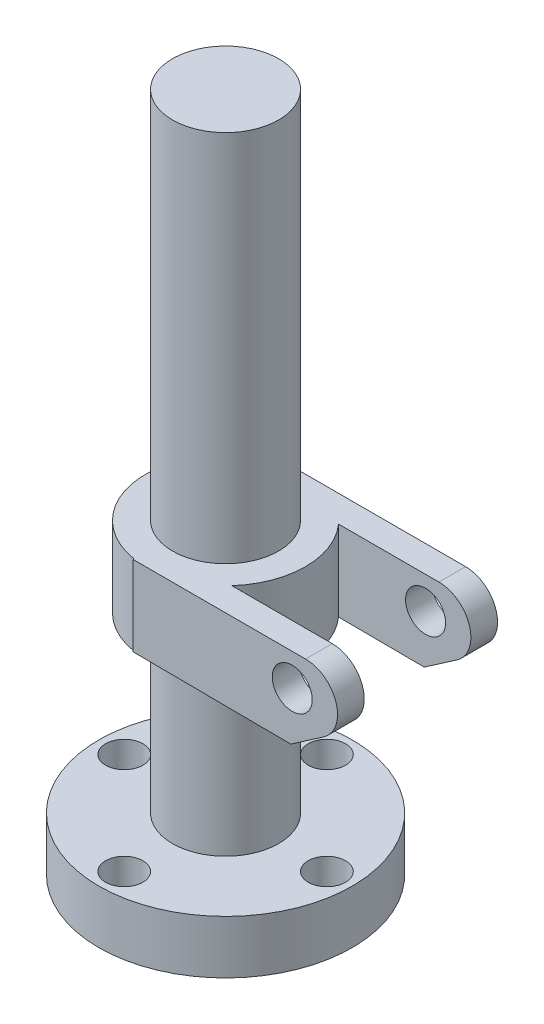
from build123d import *

# Parameters (mm, degrees)
SKETCH1_R                               = 47.5
BOSS_EXTRUDE1_DEPTH                     = 20
SKETCH2_R                               = 19.9
BOSS_EXTRUDE2_DEPTH                     = 65
SKETCH3_R                               = 30
BOSS_EXTRUDE3_DEPTH                     = 30
SKETCH4_R                               = 19.9
BOSS_EXTRUDE4_DEPTH                     = 140
BOSS_EXTRUDE5_DEPTH                     = 30
BOSS_EXTRUDE5_DEPTH_BACK                = 30
CUT_EXTRUDE1_START                      = -40
CUT_EXTRUDE1_DEPTH                      = 40
SKETCH7_R                               = 7.5
CUT_EXTRUDE2_DEPTH                      = 277.071095916
SKETCH8_R                               = 20
CUT_EXTRUDE3_DEPTH                      = 15
CBORE_FOR_M5_HEX_HEAD_BOLT3_D           = 10
CBORE_FOR_M5_HEX_HEAD_BOLT3_CBORE_D     = 14
CBORE_FOR_M5_HEX_HEAD_BOLT3_CBORE_DEPTH = 10
CIRPATTERN1_COUNT                       = 4


with BuildPart() as part:
    # Sketch1 → Boss-Extrude1 (new body)
    with BuildSketch(Plane(origin=(0, 0, 0), x_dir=(1, 0, 0), z_dir=(0, 1, 0))):
        Circle(SKETCH1_R)
    extrude(amount=BOSS_EXTRUDE1_DEPTH)

    # Sketch2 → Boss-Extrude2 (add)
    with BuildSketch(Plane(origin=(0, 20, 0), x_dir=(1, 0, 0), z_dir=(0, 1, 0))):
        Circle(SKETCH2_R)
    extrude(amount=BOSS_EXTRUDE2_DEPTH)

    # Sketch3 → Boss-Extrude3 (add)
    with BuildSketch(Plane(origin=(0, 85, 0), x_dir=(1, 0, 0), z_dir=(0, 1, 0))):
        Circle(SKETCH3_R)
    extrude(amount=BOSS_EXTRUDE3_DEPTH)

    # Sketch4 → Boss-Extrude4 (add)
    with BuildSketch(Plane(origin=(0, 115, 0), x_dir=(1, 0, 0), z_dir=(0, 1, 0))):
        Circle(SKETCH4_R)
    extrude(amount=BOSS_EXTRUDE4_DEPTH)

    # Sketch5 → Boss-Extrude5 (add, two sides: drawn at the far end of the back side and taken through both)
    with BuildSketch(Plane.XY.offset(-BOSS_EXTRUDE5_DEPTH_BACK)):
        with BuildLine():
            Line((-4.684895629, 115), (60, 115))
            ThreePointArc((60, 115), (71.456034828, 106.572011481), (66.820181321, 93.126544336))
            Line((66.820181321, 93.126544336), (54.485559633, 84.606289695))
            Line((54.485559633, 84.606289695), (-4.684895629, 85))
            Line((-4.684895629, 85), (-4.684895629, 115))
        make_face()
    extrude(amount=BOSS_EXTRUDE5_DEPTH + BOSS_EXTRUDE5_DEPTH_BACK)

    # Sketch6 → Cut-Extrude1 (cut)
    with BuildSketch(Plane(origin=(0, 115, 0), x_dir=(1, 0, 0), z_dir=(0, 1, 0)).offset(CUT_EXTRUDE1_START)):
        with BuildLine():
            Line((85.613181264, 20), (85.613181264, -20))
            Line((85.613181264, -20), (22.360679775, -20))
            ThreePointArc((22.360679775, -20), (30, 0), (22.360679775, 20))
            Line((22.360679775, 20), (85.613181264, 20))
        make_face()
    extrude(amount=CUT_EXTRUDE1_DEPTH, mode=Mode.SUBTRACT)

    # Sketch7 → Cut-Extrude2 (cut, through all)
    with BuildSketch(Plane.XY.offset(30)):
        with Locations((55, 103)):
            Circle(SKETCH7_R)
    extrude(amount=-CUT_EXTRUDE2_DEPTH, mode=Mode.SUBTRACT)

    # Sketch8 → Cut-Extrude3 (cut)
    with BuildSketch(Plane.XZ):
        Circle(SKETCH8_R)
    extrude(amount=-CUT_EXTRUDE3_DEPTH, mode=Mode.SUBTRACT)

    # CBORE for M5 Hex Head Bolt3 (through all)
    with Locations(Plane(origin=(0, 20, 0), x_dir=(1, 0, 0), z_dir=(0, 1, 0))):
        with Locations((0, 38)):
            cbore_for_m5_hex_head_bolt3 = CounterBoreHole(CBORE_FOR_M5_HEX_HEAD_BOLT3_D / 2, CBORE_FOR_M5_HEX_HEAD_BOLT3_CBORE_D / 2, CBORE_FOR_M5_HEX_HEAD_BOLT3_CBORE_DEPTH)

    # CirPattern1: CBORE for M5 Hex Head Bolt3 ×4 about axis
    cirpattern1_axis = Axis((0, 20, 0), (0, 1, 0))
    for i in range(1, CIRPATTERN1_COUNT):
        add(cbore_for_m5_hex_head_bolt3.rotate(cirpattern1_axis, i * 360 / CIRPATTERN1_COUNT), mode=Mode.SUBTRACT)


solid = part.part
